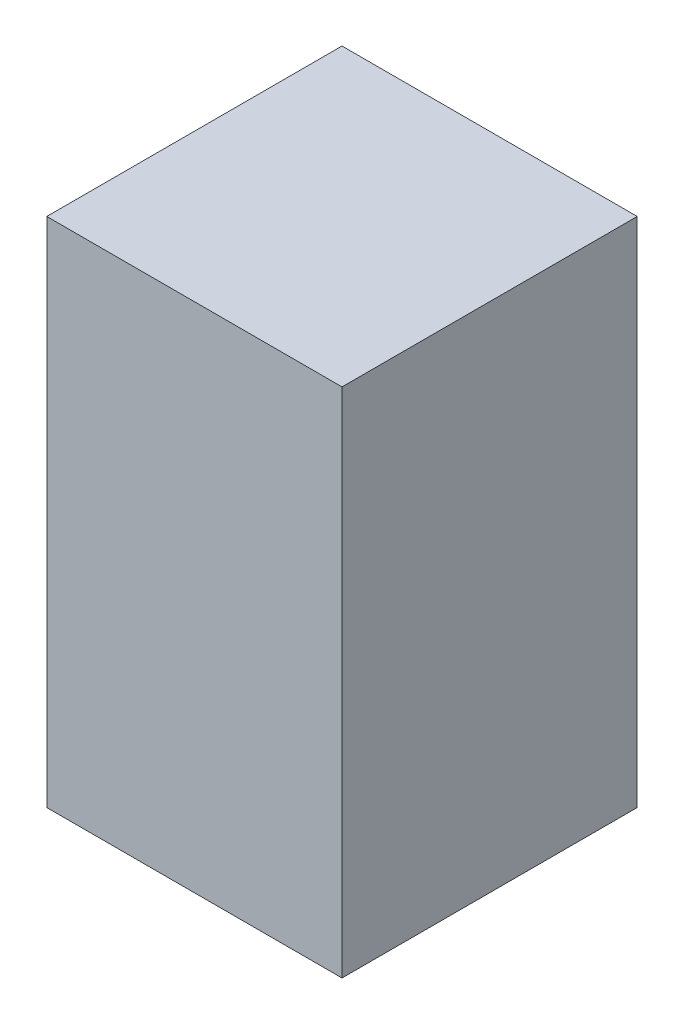
from build123d import *

# Parameters (mm, degrees)
SKETCH1_W                = 500
SKETCH1_H                = 500
BOSS_EXTRUDE1_DEPTH      = 807
BOSS_EXTRUDE1_DEPTH_BACK = 60


with BuildPart() as part:
    # Sketch1 → Boss-Extrude1 (new body, two sides)
    with BuildSketch(Plane(origin=(0, 0, 0), x_dir=(1, 0, 0), z_dir=(0, 1, 0))) as boss_extrude1_sk:
        Rectangle(SKETCH1_W, SKETCH1_H)
    extrude(amount=BOSS_EXTRUDE1_DEPTH)
    extrude(boss_extrude1_sk.sketch, amount=-BOSS_EXTRUDE1_DEPTH_BACK)


solid = part.part
